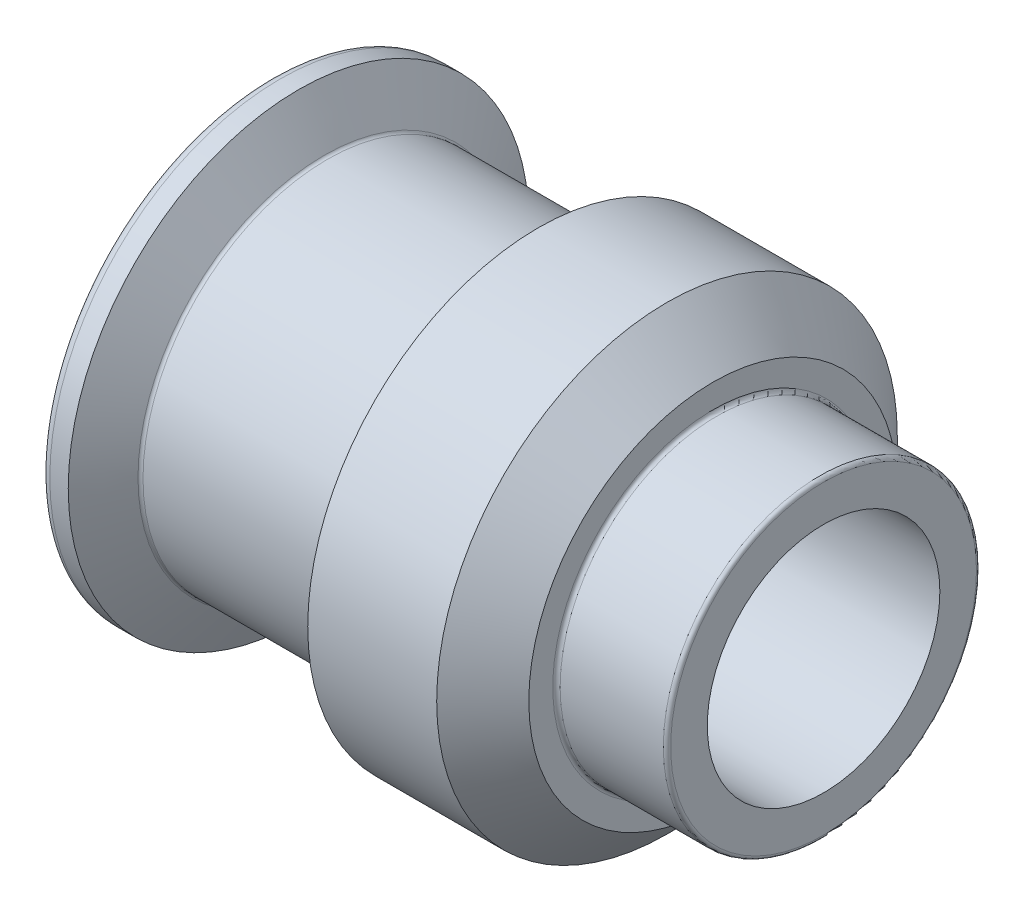
from build123d import *


with BuildPart() as part:
    # Sketch1 → Base-Revolve (revolve)
    with BuildSketch(Plane.XY):
        with BuildLine():
            Line((0, 12.625), (0, 16.6))
            ThreePointArc((0, 16.6), (-0.117157288, 16.882842712), (-0.4, 17))
            Line((-0.4, 17), (-11.6, 17))
            ThreePointArc((-11.6, 17), (-11.882842712, 17.117157288), (-12, 17.4))
            Line((-12, 17.4), (-12, 20))
            Line((-12, 20), (-17, 25))
            Line((-17, 25), (-31, 25))
            Line((-31, 25), (-33.771281292, 20.2))
            ThreePointArc((-33.771281292, 20.2), (-33.917691454, 20.053589838), (-34.117691454, 20))
            Line((-34.117691454, 20), (-53.882308546, 20))
            ThreePointArc((-53.882308546, 20), (-54.082308546, 20.053589838), (-54.228718708, 20.2))
            Line((-54.228718708, 20.2), (-57, 25))
            Line((-57, 25), (-59, 25))
            ThreePointArc((-59, 25), (-59.707106781, 24.707106781), (-60, 24))
            Line((-60, 24), (-60, 7))
            Line((-60, 7), (-30.247595264, 7))
            Line((-30.247595264, 7), (-27, 12.625))
            Line((-27, 12.625), (0, 12.625))
        make_face()
    revolve(axis=Axis((0, 0, 0), (-1, 0, 0)))


solid = part.part
